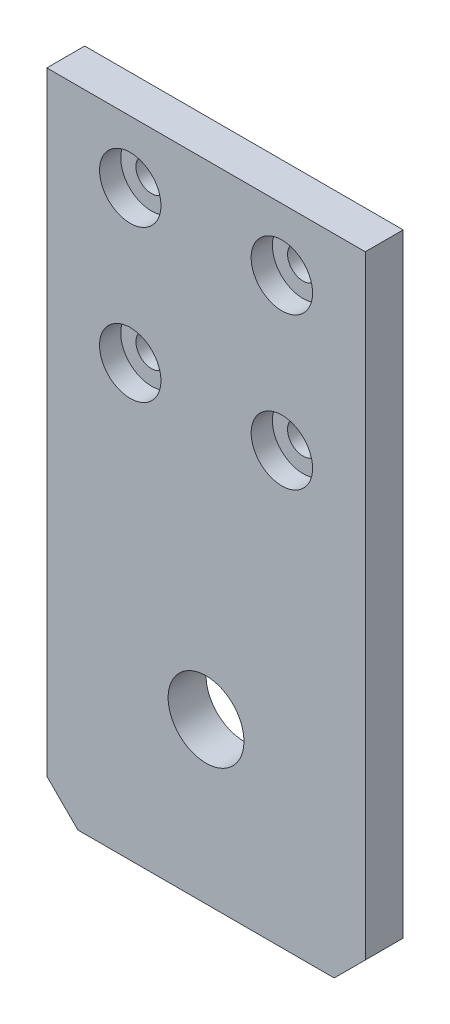
from build123d import *

# Parameters (mm, degrees)
CROQUIS1_W              = 42
CROQUIS1_H              = 85
CROQUIS1_R              = 2.05
SALIENTE_EXTRUIR1_DEPTH = 5
CROQUIS4_R              = 4.05
CORTAR_EXTRUIR1_DEPTH   = 2.8
CHAFL_N1_SIZE           = 4.1
CROQUIS7_R              = 5
CORTAR_EXTRUIR4_DEPTH   = 6


with BuildPart() as part:
    # Croquis1 → Saliente-Extruir1 (new body)
    with BuildSketch(Plane.XY):
        with Locations((21, 42.5)):
            Rectangle(CROQUIS1_W, CROQUIS1_H)
        with Locations((11, 76.8)):
            Circle(CROQUIS1_R, mode=Mode.SUBTRACT)
        with Locations((31, 76.8)):
            Circle(CROQUIS1_R, mode=Mode.SUBTRACT)
        with Locations((31, 56.8)):
            Circle(CROQUIS1_R, mode=Mode.SUBTRACT)
        with Locations((11, 56.8)):
            Circle(CROQUIS1_R, mode=Mode.SUBTRACT)
    extrude(amount=SALIENTE_EXTRUIR1_DEPTH)

    # Croquis4 → Cortar-Extruir1 (cut)
    with BuildSketch(Plane.XY.offset(5)):
        with Locations((11, 76.8)):
            Circle(CROQUIS4_R)
        with Locations((11, 56.8)):
            Circle(CROQUIS4_R)
        with Locations((31, 56.8)):
            Circle(CROQUIS4_R)
        with Locations((31, 76.8)):
            Circle(CROQUIS4_R)
    extrude(amount=-CORTAR_EXTRUIR1_DEPTH, mode=Mode.SUBTRACT)

    # Chaflán1
    chafl_n1_edges = [part.edges().sort_by_distance(p)[0] for p in [
        (42, 0, 2.5),
        (0, 0, 2.5),
    ]]
    chamfer(chafl_n1_edges, length=CHAFL_N1_SIZE)

    # Croquis7 → Cortar-Extruir4 (cut, through all)
    with BuildSketch(Plane.XY.offset(5)):
        with Locations((21, 21.08)):
            Circle(CROQUIS7_R)
    extrude(amount=-CORTAR_EXTRUIR4_DEPTH, mode=Mode.SUBTRACT)


solid = part.part
